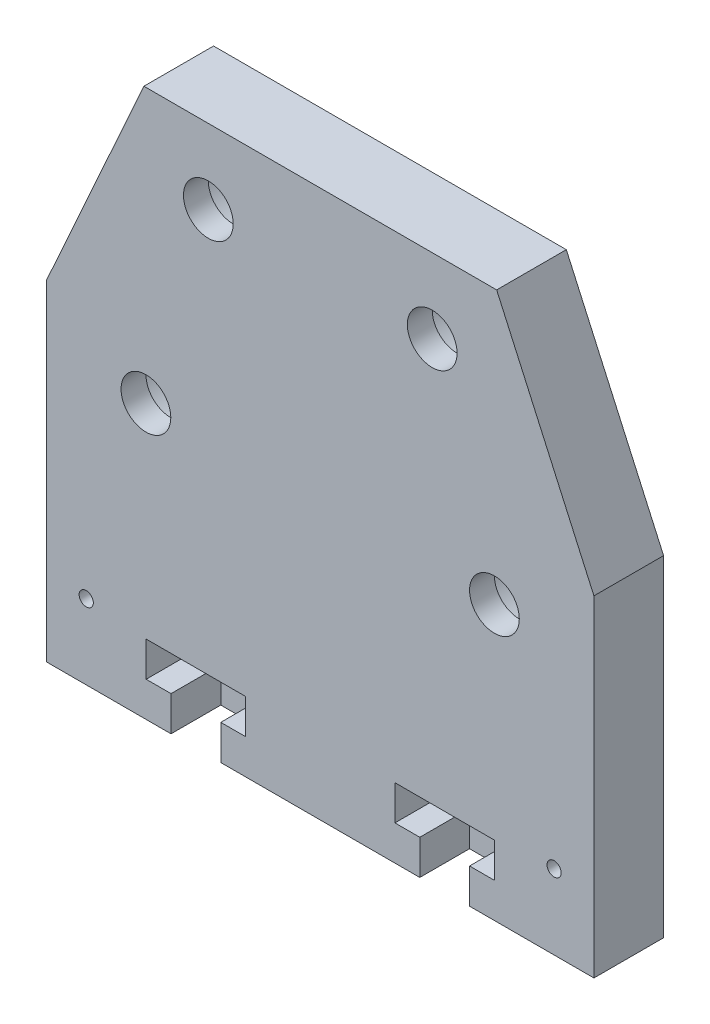
from build123d import *

# Parameters (mm, degrees)
SKETCH3_R           = 11.05
BOSS_EXTRUDE1_DEPTH = 14
SKETCH5_W           = 10
SKETCH5_H           = 7
CUT_EXTRUDE3_DEPTH  = 10
SKETCH6_R           = 11.05
SKETCH6_R_2         = 6
BOSS_EXTRUDE4_DEPTH = 5
SKETCH8_R           = 1.425
CUT_EXTRUDE5_DEPTH  = 14
SKETCH4_R           = 11.05
SKETCH4_R_2         = 5
BOSS_EXTRUDE2_DEPTH = 5


with BuildPart() as part:
    # Sketch3 → Boss-Extrude1 (new body)
    with BuildSketch(Plane.XY):
        Polygon((33.782364808, 5.02173913), (14.187228367, -38.569578566), (14.187228367, -104.97826087), (124.228904722, -104.97826087), (124.228904722, -38.463609741), (104.681403308, 5.02173913), align=None)
        with Locations((91.728904722, -9.97826087)):
            Circle(SKETCH3_R, mode=Mode.SUBTRACT)
        with Locations((46.728904722, -9.97826087)):
            Circle(SKETCH3_R, mode=Mode.SUBTRACT)
        with Locations((104.228904722, -49.97826087)):
            Circle(SKETCH3_R, mode=Mode.SUBTRACT)
        with Locations((34.187228367, -49.97826087)):
            Circle(SKETCH3_R, mode=Mode.SUBTRACT)
    extrude(amount=BOSS_EXTRUDE1_DEPTH)

    # Sketch5 → Cut-Extrude3 (cut)
    with BuildSketch(Plane.XY.offset(14)):
        Polygon((34.231884058, -97.97826087), (39.231884058, -97.97826087), (49.231884058, -97.97826087), (54.231884058, -97.97826087), (54.231884058, -90.97826087), (34.231884058, -90.97826087), align=None)
        with Locations((44.231884058, -101.47826087)):
            Rectangle(SKETCH5_W, SKETCH5_H)
        Polygon((84.231884058, -97.97826087), (89.231884058, -97.97826087), (99.231884058, -97.97826087), (104.231884058, -97.97826087), (104.231884058, -90.97826087), (84.231884058, -90.97826087), align=None)
        with Locations((94.231884058, -101.47826087)):
            Rectangle(SKETCH5_W, SKETCH5_H)
    extrude(amount=-CUT_EXTRUDE3_DEPTH, mode=Mode.SUBTRACT)

    # Sketch6 → Boss-Extrude4 (add)
    with BuildSketch(Plane.XY.offset(14)):
        with Locations((46.728904722, -9.97826087)):
            Circle(SKETCH6_R)
        with Locations((46.728904722, -9.97826087)):
            Circle(SKETCH6_R_2, mode=Mode.SUBTRACT)
        with Locations((91.728904722, -9.97826087)):
            Circle(SKETCH6_R)
        with Locations((91.728904722, -9.97826087)):
            Circle(SKETCH6_R_2, mode=Mode.SUBTRACT)
        with Locations((34.187228367, -49.97826087)):
            Circle(SKETCH6_R)
        with Locations((34.187228367, -49.97826087)):
            Circle(SKETCH6_R_2, mode=Mode.SUBTRACT)
        with Locations((104.228904722, -49.97826087)):
            Circle(SKETCH6_R)
        with Locations((104.228904722, -49.97826087)):
            Circle(SKETCH6_R_2, mode=Mode.SUBTRACT)
    extrude(amount=-BOSS_EXTRUDE4_DEPTH)

    # Sketch8 → Cut-Extrude5 (cut)
    with BuildSketch(Plane.XY.offset(14)):
        with Locations((22.187228367, -89.97826087)):
            Circle(SKETCH8_R)
        with Locations((116.228904722, -89.97826087)):
            Circle(SKETCH8_R)
    extrude(amount=-CUT_EXTRUDE5_DEPTH, mode=Mode.SUBTRACT)

    # Sketch4 → Boss-Extrude2 (add)
    with BuildSketch(Plane.XY.offset(14)):
        with Locations((46.728904722, -9.97826087)):
            Circle(SKETCH4_R)
        with Locations((46.728904722, -9.97826087)):
            Circle(SKETCH4_R_2, mode=Mode.SUBTRACT)
        with Locations((91.728904722, -9.97826087)):
            Circle(SKETCH4_R)
        with Locations((91.728904722, -9.97826087)):
            Circle(SKETCH4_R_2, mode=Mode.SUBTRACT)
        with Locations((104.228904722, -49.97826087)):
            Circle(SKETCH4_R)
        with Locations((104.228904722, -49.97826087)):
            Circle(SKETCH4_R_2, mode=Mode.SUBTRACT)
        with Locations((34.187228367, -49.97826087)):
            Circle(SKETCH4_R)
        with Locations((34.187228367, -49.97826087)):
            Circle(SKETCH4_R_2, mode=Mode.SUBTRACT)
    extrude(amount=-BOSS_EXTRUDE2_DEPTH)


solid = part.part
